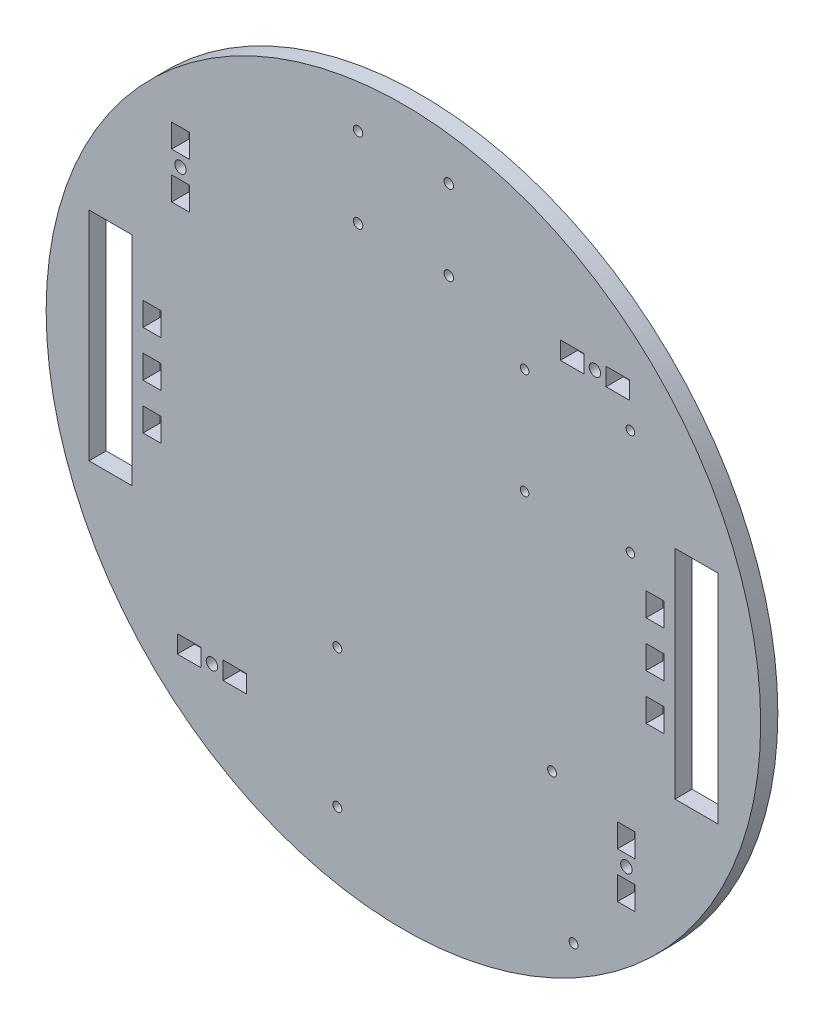
from build123d import *

# Parameters (mm, degrees)
ESQUISSE1_R                  = 125
BOSS_EXTRU_1_DEPTH           = 6
ESQUISSE2_W                  = 15
ESQUISSE2_H                  = 76
ENL_V_MAT_EXTRU_1_DEPTH      = 177.878489365
ESQUISSE3_R                  = 2
ESQUISSE3_W                  = 8.2
ESQUISSE3_H                  = 6.2
ENL_V_MAT_EXTRU_2_DEPTH      = 177.878489365
R_P_TITION_CIRCULAIRE1_COUNT = 4
ESQUISSE4_W                  = 6.2
ESQUISSE4_H                  = 8.2
ENL_V_MAT_EXTRU_3_DEPTH      = 177.878489365
ESQUISSE7_R                  = 1.5621
ENL_V_MAT_EXTRU_6_DEPTH      = 6
ESQUISSE8_R                  = 1.5
ENL_V_MAT_EXTRU_7_DEPTH      = 10
ENL_V_MAT_EXTRU_8_REACH      = 178.878
ESQUISSE9_R                  = 1.65


with BuildPart() as part:
    # Esquisse1 → Boss.-Extru.1 (new body)
    with BuildSketch(Plane.XY):
        Circle(ESQUISSE1_R)
    extrude(amount=BOSS_EXTRU_1_DEPTH)

    # Esquisse2 → Enlèv. mat.-Extru.1 (cut, through all)
    with BuildSketch(Plane.XY.offset(6)):
        with Locations((-102.5, 0)):
            Rectangle(ESQUISSE2_W, ESQUISSE2_H)
    enl_v_mat_extru_1 = extrude(amount=-ENL_V_MAT_EXTRU_1_DEPTH, mode=Mode.SUBTRACT)

    # Symétrie1: Enlèv. mat.-Extru.1 across plane
    add(enl_v_mat_extru_1.mirror(Plane(origin=(0, 0, 0), x_dir=(0, 0, 1), z_dir=(1, 0, 0))), mode=Mode.SUBTRACT)

    # Esquisse3 → Enlèv. mat.-Extru.2 (cut, through all)
    with BuildSketch(Plane(origin=(0, 0, 0), x_dir=(-1, 0, 0), z_dir=(0, 0, -1))):
        with Locations((-67, 78)):
            Circle(ESQUISSE3_R)
        with Locations((-75, 78)):
            Rectangle(ESQUISSE3_W, ESQUISSE3_H)
        with Locations((-59, 78)):
            Rectangle(ESQUISSE3_W, ESQUISSE3_H)
    enl_v_mat_extru_2 = extrude(amount=-ENL_V_MAT_EXTRU_2_DEPTH, mode=Mode.SUBTRACT)

    # Répétition circulaire1: Enlèv. mat.-Extru.2 ×4 about axis
    r_p_tition_circulaire1_axis = Axis((0, 0, -0.25), (0, 0, 1))
    for i in range(1, R_P_TITION_CIRCULAIRE1_COUNT):
        add(enl_v_mat_extru_2.rotate(r_p_tition_circulaire1_axis, i * 360 / R_P_TITION_CIRCULAIRE1_COUNT), mode=Mode.SUBTRACT)

    # Esquisse4 → Enlèv. mat.-Extru.3 (cut, through all)
    with BuildSketch(Plane(origin=(0, 0, 0), x_dir=(-1, 0, 0), z_dir=(0, 0, -1))):
        with Locations((88, 16)):
            Rectangle(ESQUISSE4_W, ESQUISSE4_H)
        with Locations((88, -16)):
            Rectangle(ESQUISSE4_W, ESQUISSE4_H)
        with Locations((88, 0)):
            Rectangle(ESQUISSE4_W, ESQUISSE4_H)
    enl_v_mat_extru_3 = extrude(amount=-ENL_V_MAT_EXTRU_3_DEPTH, mode=Mode.SUBTRACT)

    # Symétrie2: Enlèv. mat.-Extru.3 across plane
    add(enl_v_mat_extru_3.mirror(Plane(origin=(0, 0, 0), x_dir=(0, 0, 1), z_dir=(1, 0, 0))), mode=Mode.SUBTRACT)

    # Esquisse7 → Enlèv. mat.-Extru.6 (cut)
    with BuildSketch(Plane(origin=(0, 0, 0), x_dir=(-1, 0, 0), z_dir=(0, 0, -1))):
        with Locations((23.116017499, -99.394574208)):
            Circle(ESQUISSE7_R)
        with Locations((23.116017499, -51.058374208)):
            Circle(ESQUISSE7_R)
        with Locations((-52.017182501, -51.058374208)):
            Circle(ESQUISSE7_R)
        with Locations((-59.510182501, -99.394574208)):
            Circle(ESQUISSE7_R)
    extrude(amount=-ENL_V_MAT_EXTRU_6_DEPTH, mode=Mode.SUBTRACT)

    # Esquisse8 → Enlèv. mat.-Extru.7 (cut)
    with BuildSketch(Plane(origin=(0, 0, 0), x_dir=(-1, 0, 0), z_dir=(0, 0, -1))):
        with Locations((-79.404950976, 65.925052584)):
            Circle(ESQUISSE8_R)
        with Locations((-42.404950976, 65.925052584)):
            Circle(ESQUISSE8_R)
        with Locations((-42.404950976, 28.925052584)):
            Circle(ESQUISSE8_R)
        with Locations((-79.404950976, 28.925052584)):
            Circle(ESQUISSE8_R)
    extrude(amount=-ENL_V_MAT_EXTRU_7_DEPTH, mode=Mode.SUBTRACT)

    # Esquisse9 → Enlèv. mat.-Extru.8 (cut, up to next)
    with BuildSketch(Plane.XY.offset(6), mode=Mode.PRIVATE) as enl_v_mat_extru_8_sk1:
        with Locations((-15.875, 108.97)):
            Circle(ESQUISSE9_R)
    enl_v_mat_extru_8_tool1 = extrude(enl_v_mat_extru_8_sk1.sketch, amount=-ENL_V_MAT_EXTRU_8_REACH, mode=Mode.PRIVATE) & part.part
    # Esquisse9 → Enlèv. mat.-Extru.8 (cut, up to next)
    with BuildSketch(Plane.XY.offset(6), mode=Mode.PRIVATE) as enl_v_mat_extru_8_sk2:
        with Locations((15.875, 108.97)):
            Circle(ESQUISSE9_R)
    enl_v_mat_extru_8_tool2 = extrude(enl_v_mat_extru_8_sk2.sketch, amount=-ENL_V_MAT_EXTRU_8_REACH, mode=Mode.PRIVATE) & part.part
    # Esquisse9 → Enlèv. mat.-Extru.8 (cut, up to next)
    with BuildSketch(Plane.XY.offset(6), mode=Mode.PRIVATE) as enl_v_mat_extru_8_sk3:
        with Locations((15.875, 81.03)):
            Circle(ESQUISSE9_R)
    enl_v_mat_extru_8_tool3 = extrude(enl_v_mat_extru_8_sk3.sketch, amount=-ENL_V_MAT_EXTRU_8_REACH, mode=Mode.PRIVATE) & part.part
    # Esquisse9 → Enlèv. mat.-Extru.8 (cut, up to next)
    with BuildSketch(Plane.XY.offset(6), mode=Mode.PRIVATE) as enl_v_mat_extru_8_sk4:
        with Locations((-15.875, 81.03)):
            Circle(ESQUISSE9_R)
    enl_v_mat_extru_8_tool4 = extrude(enl_v_mat_extru_8_sk4.sketch, amount=-ENL_V_MAT_EXTRU_8_REACH, mode=Mode.PRIVATE) & part.part
    add(enl_v_mat_extru_8_tool1.solids().sort_by_distance((-15.875, 108.97, 6))[0], mode=Mode.SUBTRACT)
    add(enl_v_mat_extru_8_tool2.solids().sort_by_distance((15.875, 108.97, 6))[0], mode=Mode.SUBTRACT)
    add(enl_v_mat_extru_8_tool3.solids().sort_by_distance((15.875, 81.03, 6))[0], mode=Mode.SUBTRACT)
    add(enl_v_mat_extru_8_tool4.solids().sort_by_distance((-15.875, 81.03, 6))[0], mode=Mode.SUBTRACT)


solid = part.part
